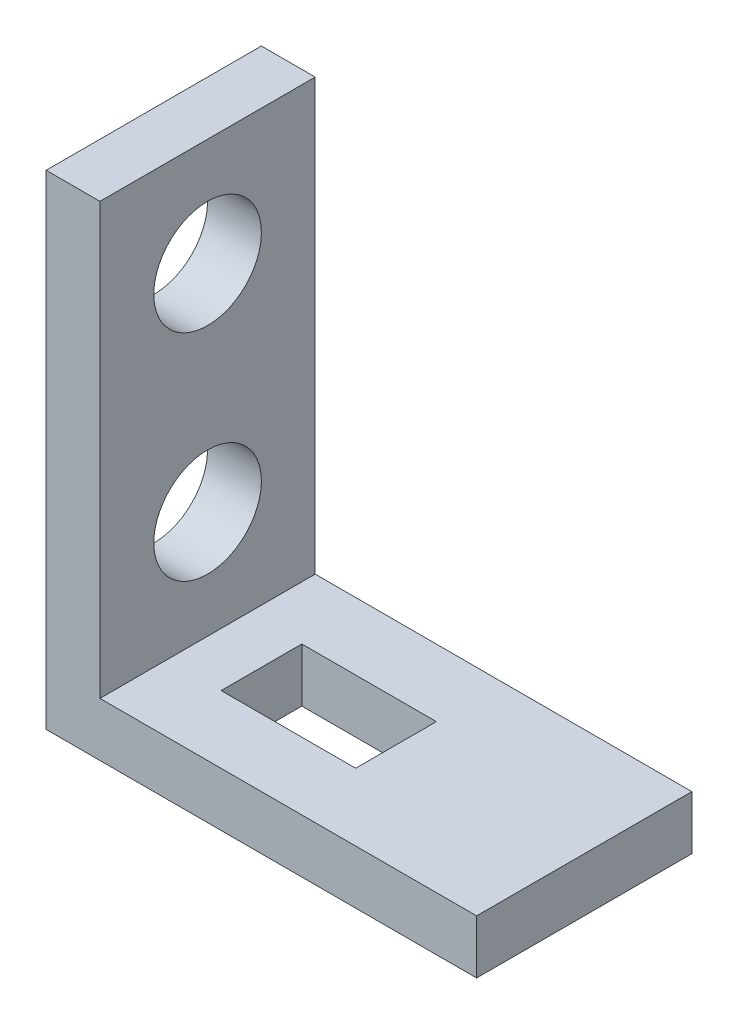
from build123d import *

# Parameters (mm, degrees)
BOSS_EXTRUDE1_DEPTH = 12.7
SKETCH2_R           = 3.175
CUT_EXTRUDE1_DEPTH  = 4.175
SKETCH4_W           = 7.9375
SKETCH4_H           = 4.7625
CUT_EXTRUDE2_DEPTH  = 4.175


with BuildPart() as part:
    # Sketch1 → Boss-Extrude1 (new body)
    with BuildSketch(Plane.XY):
        Polygon((0, 0), (25.4, 0), (25.4, 3.175), (3.175, 3.175), (3.175, 28.575), (0, 28.575), align=None)
    extrude(amount=BOSS_EXTRUDE1_DEPTH)

    # Sketch2 → Cut-Extrude1 (cut, through all)
    with BuildSketch(Plane(origin=(3.175, 0, 0), x_dir=(0, 0, -1), z_dir=(1, 0, 0))):
        with Locations((-6.35, 22.225)):
            Circle(SKETCH2_R)
        with Locations((-6.35, 9.525)):
            Circle(SKETCH2_R)
    extrude(amount=-CUT_EXTRUDE1_DEPTH, mode=Mode.SUBTRACT)

    # Sketch4 → Cut-Extrude2 (cut, through all)
    with BuildSketch(Plane(origin=(0, 3.175, 0), x_dir=(1, 0, 0), z_dir=(0, 1, 0))):
        with Locations((10.31875, -6.34365)):
            Rectangle(SKETCH4_W, SKETCH4_H)
    extrude(amount=-CUT_EXTRUDE2_DEPTH, mode=Mode.SUBTRACT)


solid = part.part
